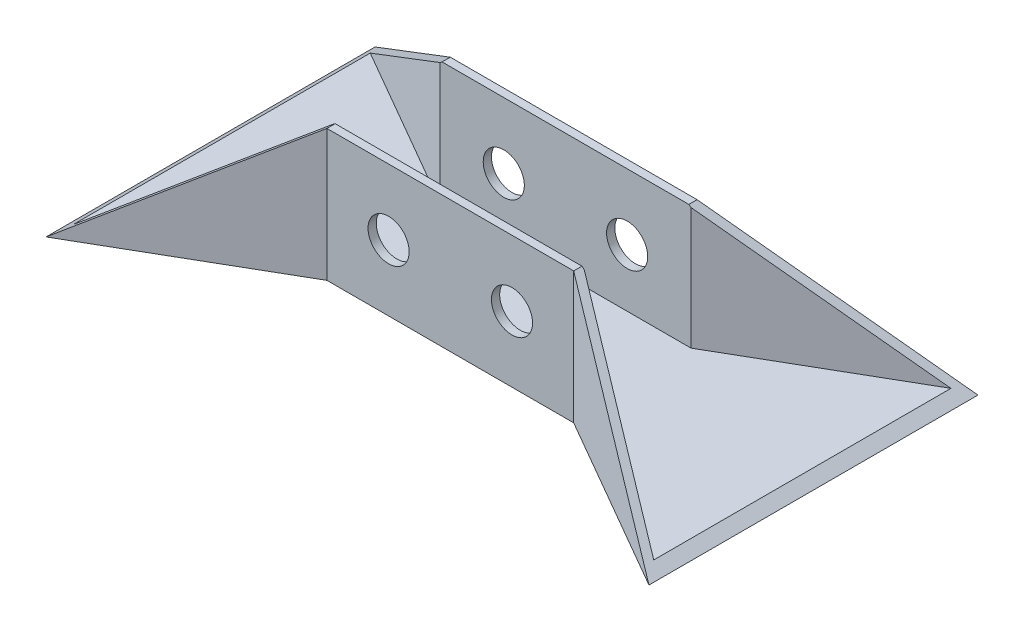
from build123d import *

# Parameters (mm, degrees)
BOSS_EXTRUDE1_DEPTH     = 5
BOSS_EXTRUDE2_DEPTH     = 75
CUT_EXTRUDE1_DEPTH      = 101
CUT_EXTRUDE1_DEPTH_BACK = 101
SKETCH4_R               = 12.5
CUT_EXTRUDE2_DEPTH      = 101
CUT_EXTRUDE2_DEPTH_BACK = 101


with BuildPart() as part:
    # Sketch1 → Boss-Extrude1 (new body)
    with BuildSketch(Plane(origin=(0, 0, 0), x_dir=(1, 0, 0), z_dir=(0, 1, 0))):
        Polygon((-183.253175473, 100), (-183.253175473, -100), (-75, -37.5), (75, -37.5), (183.253175473, -100), (183.253175473, 100), (75, 37.5), (-75, 37.5), align=None)
    extrude(amount=BOSS_EXTRUDE1_DEPTH)

    # Sketch2 → Boss-Extrude2 (add)
    with BuildSketch(Plane(origin=(0, 5, 0), x_dir=(1, 0, 0), z_dir=(0, 1, 0))):
        Polygon((-183.253175473, -100), (-75, -37.5), (75, -37.5), (183.253175473, -100), (183.253175473, -94.226497308), (76.339745962, -32.5), (-76.339745962, -32.5), (-183.253175473, -94.226497308), align=None)
        Polygon((-183.253175473, 100), (-75, 37.5), (75, 37.5), (183.253175473, 100), (183.253175473, 94.226497308), (76.339745962, 32.5), (-76.339745962, 32.5), (-183.253175473, 94.226497308), align=None)
    extrude(amount=BOSS_EXTRUDE2_DEPTH)

    # Sketch3 → Cut-Extrude1 (cut, two sides)
    with BuildSketch(Plane.XY) as cut_extrude1_sk:
        Polygon((-183.253175473, 0), (-75, 80), (-183.253175473, 80), align=None)
        Polygon((183.253175473, 0), (75, 80), (183.253175473, 80), align=None)
    extrude(amount=CUT_EXTRUDE1_DEPTH, mode=Mode.SUBTRACT)
    extrude(cut_extrude1_sk.sketch, amount=-CUT_EXTRUDE1_DEPTH_BACK, mode=Mode.SUBTRACT)

    # Sketch4 → Cut-Extrude2 (cut, two sides)
    with BuildSketch(Plane.XY) as cut_extrude2_sk:
        with Locations((-37.5, 40)):
            Circle(SKETCH4_R)
        with Locations((37.5, 40)):
            Circle(SKETCH4_R)
    extrude(amount=CUT_EXTRUDE2_DEPTH, mode=Mode.SUBTRACT)
    extrude(cut_extrude2_sk.sketch, amount=-CUT_EXTRUDE2_DEPTH_BACK, mode=Mode.SUBTRACT)


solid = part.part
